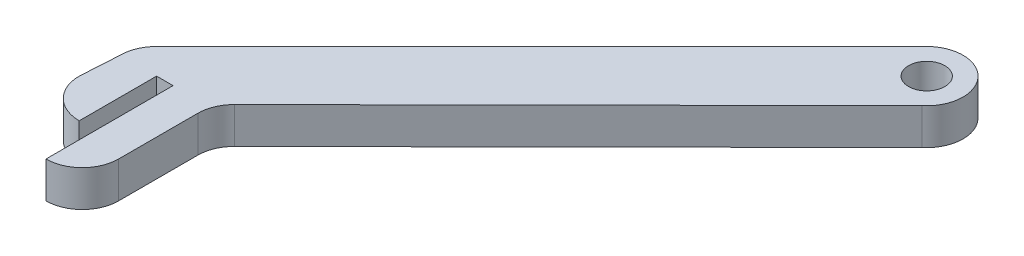
from build123d import *

# Parameters (mm, degrees)
SALIENTE_EXTRUIR1_DEPTH = 10
CROQUIS2_R              = 5
CORTAR_EXTRUIR1_DEPTH   = 11


with BuildPart() as part:
    # Croquis1 → Saliente-Extruir1 (new body)
    with BuildSketch(Plane(origin=(0, 0, 0), x_dir=(1, 0, 0), z_dir=(0, 1, 0))):
        with BuildLine():
            Line((-4.53910409, 0), (0, 0))
            Line((0, 0), (0, -35))
            ThreePointArc((0, -35), (7.071067812, -32.071067812), (10, -25))
            Line((10, -25), (10, -3.173501178))
            ThreePointArc((10, -3.173501178), (10.766393259, 0.665835552), (12.948101308, 3.916683924))
            Line((12.948101308, 3.916683924), (107.92484737, 98.380547972))
            ThreePointArc((107.92484737, 98.380547972), (108.912854015, 112.807521211), (94.455845276, 113.13708499))
            Line((94.455845276, 113.13708499), (-11.610171902, 7.071067812))
            ThreePointArc((-11.610171902, 7.071067812), (-13.777899415, 3.826834324), (-14.53910409, 0))
            Line((-14.53910409, 0), (-15.191410871, -10.652306781))
            ThreePointArc((-15.191410871, -10.652306781), (-12.07142245, -18.18462514), (-4.53910409, -21.304613561))
            Line((-4.53910409, -21.304613561), (-4.53910409, 0))
        make_face()
    extrude(amount=SALIENTE_EXTRUIR1_DEPTH)

    # Croquis2 → Cortar-Extruir1 (cut, through all)
    with BuildSketch(Plane(origin=(0, 10, 0), x_dir=(1, 0, 0), z_dir=(0, 1, 0))):
        with Locations((101.526913088, 106.066017178)):
            Circle(CROQUIS2_R)
    extrude(amount=-CORTAR_EXTRUIR1_DEPTH, mode=Mode.SUBTRACT)


solid = part.part
